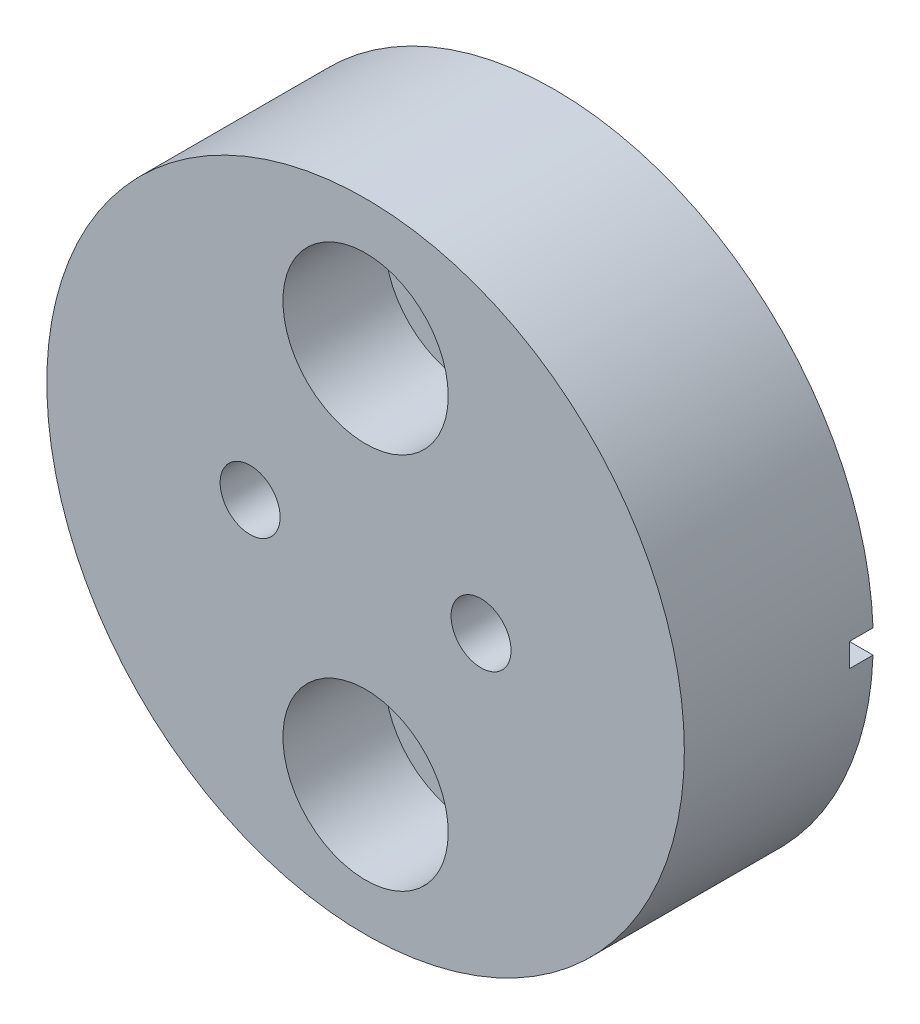
from build123d import *

# Parameters (mm, degrees)
SKETCH2_R           = 13.5
BOSS_EXTRUDE1_DEPTH = 8
SKETCH5_R           = 2.3
CUT_EXTRUDE4_DEPTH  = 10
SKETCH8_W           = 10
SKETCH8_H           = 1
CUT_EXTRUDE5_DEPTH  = 1
SKETCH11_R          = 3.5
CUT_EXTRUDE6_DEPTH  = 4.32
SKETCH12_R          = 1.27
CUT_EXTRUDE7_DEPTH  = 32.5


with BuildPart() as part:
    # Sketch2 → Boss-Extrude1 (new body)
    with BuildSketch(Plane.XY):
        Circle(SKETCH2_R)
    extrude(amount=BOSS_EXTRUDE1_DEPTH)

    # Sketch5 → Cut-Extrude4 (cut)
    with BuildSketch(Plane.XY.offset(8)):
        with Locations((0, 8)):
            Circle(SKETCH5_R)
    cut_extrude4 = extrude(amount=-CUT_EXTRUDE4_DEPTH, mode=Mode.SUBTRACT)

    # Mirror1: Cut-Extrude4 across plane
    add(cut_extrude4.mirror(Plane.ZX), mode=Mode.SUBTRACT)

    # Sketch8 → Cut-Extrude5 (cut)
    with BuildSketch(Plane(origin=(0, 0, 0), x_dir=(-1, 0, 0), z_dir=(0, 0, -1))):
        with Locations((-13.5, 0)):
            Rectangle(SKETCH8_W, SKETCH8_H)
    cut_extrude5 = extrude(amount=-CUT_EXTRUDE5_DEPTH, mode=Mode.SUBTRACT)

    # Mirror2: Cut-Extrude5 across plane
    add(cut_extrude5.mirror(Plane(origin=(0, 0, 0), x_dir=(0, 0, 1), z_dir=(1, 0, 0))), mode=Mode.SUBTRACT)

    # Sketch11 → Cut-Extrude6 (cut)
    with BuildSketch(Plane.XY.offset(8)):
        with Locations((0, 8)):
            Circle(SKETCH11_R)
    cut_extrude6 = extrude(amount=-CUT_EXTRUDE6_DEPTH, mode=Mode.SUBTRACT)

    # Mirror3: Cut-Extrude6 across plane
    add(cut_extrude6.mirror(Plane.ZX), mode=Mode.SUBTRACT)

    # Sketch12 → Cut-Extrude7 (cut)
    with BuildSketch(Plane.XY.offset(8)):
        with Locations((4.89, 0)):
            Circle(SKETCH12_R)
        with Locations((-4.89, 0)):
            Circle(SKETCH12_R)
    extrude(amount=-CUT_EXTRUDE7_DEPTH, mode=Mode.SUBTRACT)


solid = part.part
